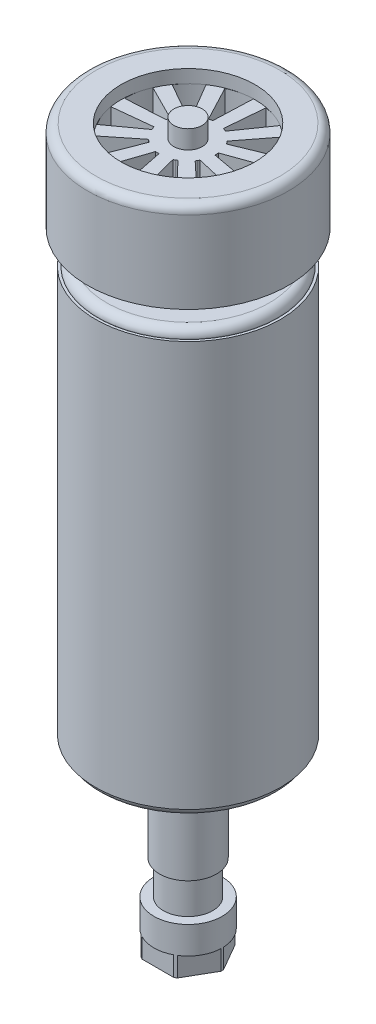
from build123d import *

# Parameters (mm, degrees)
CORTAR_EXTRUIR1_DEPTH = 22
CROQUIS5_OUTSIDE_W    = 102.148
CROQUIS5_OUTSIDE_H    = 102.148
CROQUIS5_OUTSIDE_R    = 1.5
CORTAR_EXTRUIR2_DEPTH = 5.5
CROQUIS6_R            = 1.5
CORTAR_EXTRUIR3_DEPTH = 10


with BuildPart() as part:
    # Croquis3 → Revolución1 (revolve)
    with BuildSketch(Plane.XY):
        with BuildLine():
            Line((-25.85, 65.019911999), (-18.85, 65.019911999))
            Line((-18.85, 65.019911999), (-18.85, 61.319911999))
            Line((-18.85, 61.319911999), (-4, 61.319911999))
            Line((-4, 61.319911999), (-4, 66.503346961))
            Line((-4, 66.503346961), (0, 66.503346961))
            Line((0, 66.503346961), (0, -136.580088001))
            Line((0, -136.580088001), (-9.6, -136.580088001))
            Line((-9.6, -136.580088001), (-9.6, -123.380088001))
            Line((-9.6, -123.380088001), (-6.9, -123.380088001))
            Line((-6.9, -123.380088001), (-6.9, -113.880088001))
            Line((-6.9, -113.880088001), (-8, -113.880088001))
            Line((-8, -113.880088001), (-8, -93.880088001))
            Line((-8, -93.880088001), (-4.75, -93.880088001))
            Line((-4.75, -93.880088001), (-4.75, -92.880088001))
            Line((-4.75, -92.880088001), (-13, -92.880088001))
            Line((-13, -92.880088001), (-13, -86.280088001))
            Line((-13, -86.280088001), (-22.9, -86.280088001))
            ThreePointArc((-22.9, -86.280088001), (-24.597056275, -85.577144276), (-25.3, -83.880088001))
            Line((-25.3, -83.880088001), (-25.3, -83.780088001))
            Line((-25.3, -83.780088001), (-26, -83.780088001))
            Line((-26, -83.780088001), (-26, 30.219911999))
            Line((-26, 30.219911999), (-25.3, 30.219911999))
            Line((-25.3, 30.219911999), (-25.3, 30.319911999))
            ThreePointArc((-25.3, 30.319911999), (-24.597056275, 32.016968273), (-22.9, 32.719911999))
            Line((-22.9, 32.719911999), (-13, 32.719911999))
            Line((-13, 32.719911999), (-13, 39.619911999))
            Line((-13, 39.619911999), (-28.25, 39.619911999))
            Line((-28.25, 39.619911999), (-28.25, 62.619911999))
            ThreePointArc((-28.25, 62.619911999), (-27.547056275, 64.316968273), (-25.85, 65.019911999))
        make_face()
    revolve(axis=Axis((0, 66.503346961, 0), (0, -1, 0)))

    # Croquis4 → Cortar-Extruir1 (cut)
    with BuildSketch(Plane(origin=(0, 61.319911999, 0), x_dir=(1, 0, 0), z_dir=(0, 1, 0))):
        with BuildLine():
            Line((-7.658154871, 1.479382123), (-18.690121594, 0.847087609))
            ThreePointArc((-18.690121594, 0.847087609), (-18.36871906, 4.212095184), (-17.32507143, 7.427274058))
            Line((-17.32507143, 7.427274058), (-7.454960737, 2.458873808))
            ThreePointArc((-7.454960737, 2.458873808), (-7.52975075, 2.219313777), (-7.596844825, 1.97748545))
            ThreePointArc((-7.596844825, 1.97748545), (-7.631481428, 1.728923867), (-7.658154871, 1.479382123))
        make_face()
        with BuildLine():
            Line((-5.64263548, 5.384846547), (-15.265160683, 10.817258061))
            ThreePointArc((-15.265160683, 10.817258061), (-13.175519219, 13.474319242), (-10.559290029, 15.614861321))
            Line((-10.559290029, 15.614861321), (-4.942144512, 6.098992345))
            ThreePointArc((-4.942144512, 6.098992345), (-5.134577805, 5.937896156), (-5.321763197, 5.770731017))
            ThreePointArc((-5.321763197, 5.770731017), (-5.485283899, 5.580353669), (-5.64263548, 5.384846547))
        make_face()
        with BuildLine():
            Line((-1.835619193, 7.58066024), (-6.993619113, 17.353025509))
            ThreePointArc((-6.993619113, 17.353025509), (-3.79918512, 18.458542146), (-0.441008652, 18.844840444))
            Line((-0.441008652, 18.844840444), (-0.860232323, 7.802723906))
            ThreePointArc((-0.860232323, 7.802723906), (-1.109212687, 7.771238461), (-1.357059356, 7.73181026))
            ThreePointArc((-1.357059356, 7.73181026), (-1.597547489, 7.660060609), (-1.835619193, 7.58066024))
        make_face()
        with BuildLine():
            Line((2.554193218, 7.369667869), (3.498347111, 18.379329969))
            ThreePointArc((3.498347111, 18.379329969), (6.78336341, 17.58230834), (9.817289856, 16.091715878))
            Line((9.817289856, 16.091715878), (3.49479755, 7.029145758))
            ThreePointArc((3.49479755, 7.029145758), (3.268319623, 7.137267463), (3.038501242, 7.238094376))
            ThreePointArc((3.038501242, 7.238094376), (2.79739896, 7.30775243), (2.554193218, 7.369667869))
        make_face()
        with BuildLine():
            Line((6.133067329, 4.818858021), (12.879612845, 13.570327026))
            ThreePointArc((12.879612845, 13.570327026), (15.212241987, 11.123815867), (16.9586682, 8.229585218))
            Line((16.9586682, 8.229585218), (6.740253894, 4.023863497))
            ThreePointArc((6.740253894, 4.023863497), (6.608183545, 4.237264476), (6.469359165, 4.44633467))
            ThreePointArc((6.469359165, 4.44633467), (6.304191006, 4.635284488), (6.133067329, 4.818858021))
        make_face()
        with BuildLine():
            Line((7.764735898, 0.7380948), (18.171692504, 4.452841136))
            ThreePointArc((18.171692504, 4.452841136), (18.811341218, 1.133590454), (18.715789216, -2.2453806))
            Line((18.715789216, -2.2453806), (7.845727251, -0.258966992))
            ThreePointArc((7.845727251, -0.258966992), (7.849995883, -0.008040044), (7.846241263, 0.242895122))
            ThreePointArc((7.846241263, 0.242895122), (7.80944695, 0.491146473), (7.764735898, 0.7380948))
        make_face()
        with BuildLine():
            Line((6.931155682, -3.577008305), (17.694388188, -6.078390353))
            ThreePointArc((17.694388188, -6.078390353), (16.437972526, -9.21654192), (14.530779394, -12.007453943))
            Line((14.530779394, -12.007453943), (6.460237641, -4.459577292))
            ThreePointArc((6.460237641, -4.459577292), (6.599489993, -4.250791906), (6.731997199, -4.037661911))
            ThreePointArc((6.731997199, -4.037661911), (6.835258667, -3.808927078), (6.931155682, -3.577008305))
        make_face()
        with BuildLine():
            Line((3.89698251, -6.756436547), (11.599240645, -14.679775853))
            ThreePointArc((11.599240645, -14.679775853), (8.845663703, -16.640487354), (5.732349785, -17.9572455))
            Line((5.732349785, -17.9572455), (3.023668226, -7.244303311))
            ThreePointArc((3.023668226, -7.244303311), (3.25369266, -7.143947373), (3.480391591, -7.036289816))
            ThreePointArc((3.480391591, -7.036289816), (3.690924052, -6.899693193), (3.89698251, -6.756436547))
        make_face()
        with BuildLine():
            Line((-0.374455074, -7.790743924), (1.821416153, -18.620436241))
            ThreePointArc((1.821416153, -18.620436241), (-1.555080846, -18.78119563), (-4.886060379, -18.20573849))
            Line((-4.886060379, -18.20573849), (-1.372894487, -7.729014215))
            ThreePointArc((-1.372894487, -7.729014215), (-1.125129102, -7.768950026), (-0.876213757, -7.80094542))
            ThreePointArc((-0.876213757, -7.80094542), (-0.62525287, -7.799855471), (-0.374455074, -7.790743924))
        make_face()
        with BuildLine():
            Line((-4.527005818, -6.351545152), (-8.534695097, -16.649239689))
            ThreePointArc((-8.534695097, -16.649239689), (-11.462098214, -14.959006995), (-13.953180895, -12.674038145))
            Line((-13.953180895, -12.674038145), (-5.3335729, -5.759817716))
            ThreePointArc((-5.3335729, -5.759817716), (-5.146730325, -5.927365938), (-4.954627427, -6.088855973))
            ThreePointArc((-4.954627427, -6.088855973), (-4.742916424, -6.223618748), (-4.527005818, -6.351545152))
        make_face()
        with BuildLine():
            Line((-7.242264201, -2.895775672), (-16.181100958, -9.392027173))
            ThreePointArc((-16.181100958, -9.392027173), (-17.729980386, -6.387439334), (-18.590265066, -3.11842024))
            Line((-18.590265066, -3.11842024), (-7.600879603, -1.961919789))
            ThreePointArc((-7.600879603, -1.961919789), (-7.534281034, -2.203885046), (-7.459981898, -2.443597775))
            ThreePointArc((-7.459981898, -2.443597775), (-7.354737525, -2.671427046), (-7.242264201, -2.895775672))
        make_face()
    extrude(amount=-CORTAR_EXTRUIR1_DEPTH, mode=Mode.SUBTRACT)

    # Croquis5 outside → Cortar-Extruir2 (cut)
    with BuildSketch(Plane.XZ.offset(136.580088001)):
        Rectangle(CROQUIS5_OUTSIDE_W, CROQUIS5_OUTSIDE_H)
        Polygon((9.814954576, 0), (4.907477288, 8.5), (-4.907477288, 8.5), (-9.814954576, 0), (-4.907477288, -8.5), (4.907477288, -8.5), align=None, mode=Mode.SUBTRACT)
        with Locations((-0.096894906, 0)):
            Circle(CROQUIS5_OUTSIDE_R)
    extrude(amount=-CORTAR_EXTRUIR2_DEPTH, mode=Mode.SUBTRACT)

    # Croquis6 → Cortar-Extruir3 (cut)
    with BuildSketch(Plane.XZ.offset(86.280088001)):
        with Locations((0, 17.5)):
            Circle(CROQUIS6_R)
        with Locations((17.5, 0)):
            Circle(CROQUIS6_R)
        with Locations((0, -17.5)):
            Circle(CROQUIS6_R)
        with Locations((-17.5, 0)):
            Circle(CROQUIS6_R)
    extrude(amount=-CORTAR_EXTRUIR3_DEPTH, mode=Mode.SUBTRACT)


solid = part.part
